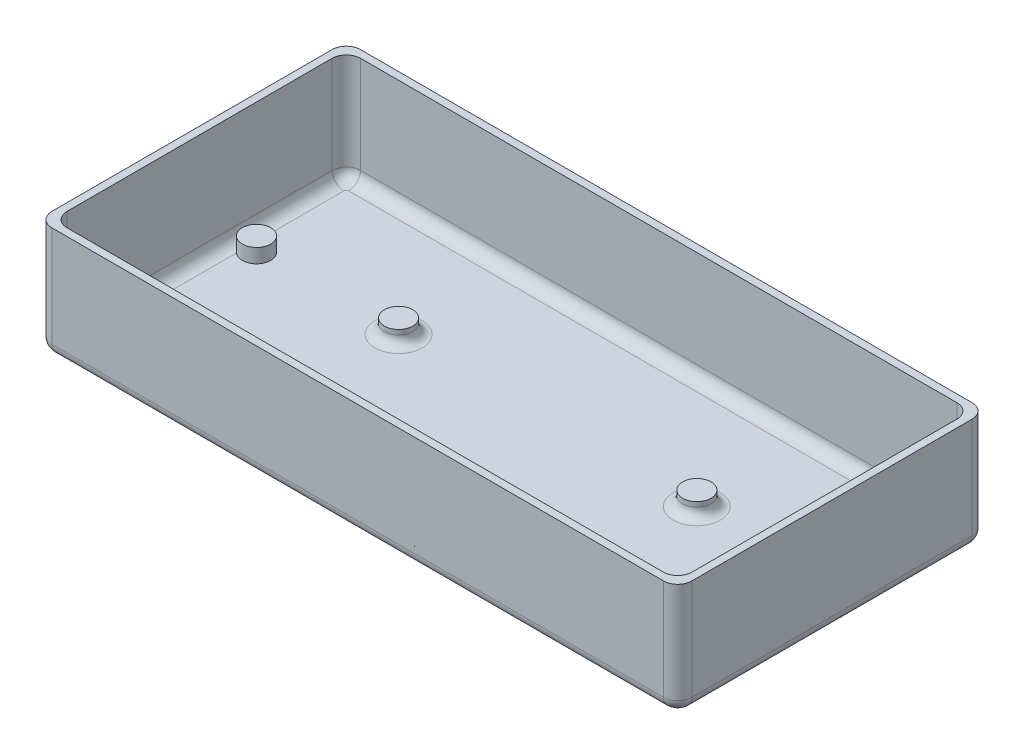
from build123d import *

# Parameters (mm, degrees)
SKETCH1_W           = 135.2
SKETCH1_H           = 65.2
SKETCH1_W_2         = 132
SKETCH1_H_2         = 62
BOSS_EXTRUDE1_DEPTH = 23
SKETCH2_W           = 135.2
SKETCH2_H           = 65.2
BOSS_EXTRUDE2_DEPTH = 0.8
FILLET1_R           = 3
FILLET2_R           = 2.5
SKETCH3_R           = 3
BOSS_EXTRUDE5_DEPTH = 3
SKETCH4_R           = 1.4
BOSS_EXTRUDE6_DEPTH = 3
FILLET3_R           = 0.8
FILLET4_R           = 2


with BuildPart() as part:
    # Sketch1 → Boss-Extrude1 (new body)
    with BuildSketch(Plane(origin=(0, 0, 0), x_dir=(1, 0, 0), z_dir=(0, 1, 0))):
        Rectangle(SKETCH1_W, SKETCH1_H)
        Rectangle(SKETCH1_W_2, SKETCH1_H_2, mode=Mode.SUBTRACT)
    extrude(amount=BOSS_EXTRUDE1_DEPTH)

    # Sketch2 → Boss-Extrude2 (add)
    with BuildSketch(Plane.XZ):
        Rectangle(SKETCH2_W, SKETCH2_H)
    extrude(amount=BOSS_EXTRUDE2_DEPTH)

    # Fillet1
    fillet1_edges = [part.edges().sort_by_distance(p)[0] for p in [
        (66, 11.5, 31),
        (66, 11.5, -31),
        (-66, 11.5, -31),
        (-66, 11.5, 31),
        (-67.6, 11.1, 32.6),
        (-67.6, 11.1, -32.6),
        (67.6, 11.1, -32.6),
        (67.6, 11.1, 32.6),
    ]]
    fillet(fillet1_edges, radius=FILLET1_R)

    # Fillet2
    fillet2_edges = [part.edges().sort_by_distance(p)[0] for p in [
        (0, -0.8, -32.6),
        (67.6, -0.8, 0),
        (0, -0.8, 32.6),
        (-67.6, -0.8, 0),
        (66.721320344, -0.8, 31.721320344),
        (-66.721320344, -0.8, 31.721320344),
        (-66.721320344, -0.8, -31.721320344),
        (66.721320344, -0.8, -31.721320344),
        (-66, 0, 0),
        (0, 0, 31),
        (66, 0, 0),
        (0, 0, -31),
        (-65.121320344, 0, -30.121320344),
        (65.121320344, 0, -30.121320344),
        (65.121320344, 0, 30.121320344),
        (-65.121320344, 0, 30.121320344),
    ]]
    fillet(fillet2_edges, radius=FILLET2_R)

    # Sketch3 → Boss-Extrude5 (add)
    with BuildSketch(Plane(origin=(0, 0, 0), x_dir=(1, 0, 0), z_dir=(0, 1, 0))):
        with Locations((-31.5, -26.5)):
            Circle(SKETCH3_R)
        with Locations((-61.5, -26.5)):
            Circle(SKETCH3_R)
        with Locations((31.5, -26.5)):
            Circle(SKETCH3_R)
        with Locations((61.5, -26.5)):
            Circle(SKETCH3_R)
        with Locations((-31.5, 7.539672284)):
            Circle(SKETCH3_R)
        with Locations((-61.5, 7.539672284)):
            Circle(SKETCH3_R)
        with Locations((31.5, 7.539672284)):
            Circle(SKETCH3_R)
        with Locations((61.5, 7.539672284)):
            Circle(SKETCH3_R)
    extrude(amount=BOSS_EXTRUDE5_DEPTH)

    # Sketch4 → Boss-Extrude6 (add)
    with BuildSketch(Plane(origin=(0, 3, 0), x_dir=(1, 0, 0), z_dir=(0, 1, 0))):
        with Locations((-61.5, -26.5)):
            Circle(SKETCH4_R)
        with Locations((-31.5, -26.5)):
            Circle(SKETCH4_R)
        with Locations((31.5, -26.5)):
            Circle(SKETCH4_R)
        with Locations((61.5, -26.5)):
            Circle(SKETCH4_R)
    extrude(amount=BOSS_EXTRUDE6_DEPTH)

    # Fillet3
    fillet3_edges = [part.edges().sort_by_distance(p)[0] for p in [
        (-62.9, 3, 26.5),
        (-32.9, 3, 26.5),
        (30.1, 3, 26.5),
        (60.1, 3, 26.5),
    ]]
    fillet(fillet3_edges, radius=FILLET3_R)

    # Fillet4
    fillet4_edges = [part.edges().sort_by_distance(p)[0] for p in [
        (-34.5, 0, -7.539672284),
        (28.5, 0, -7.539672284),
    ]]
    fillet(fillet4_edges, radius=FILLET4_R)


solid = part.part
